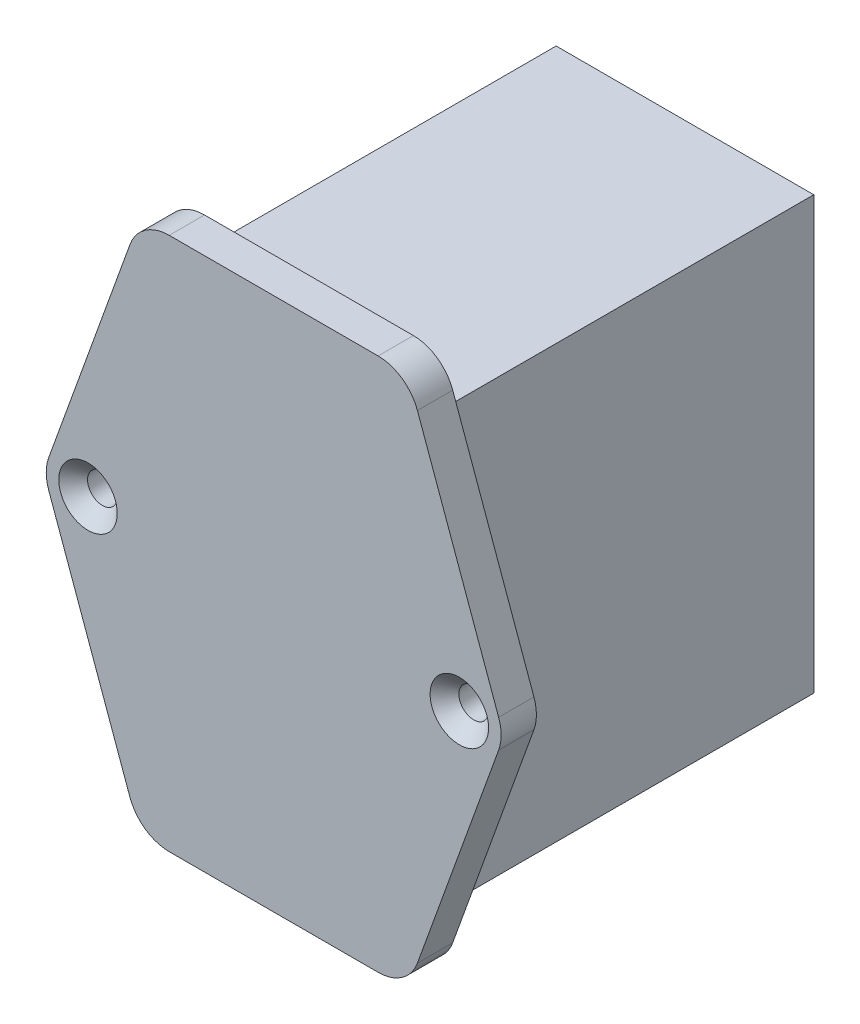
from build123d import *

# Parameters (mm, degrees)
SKETCH1_W                                       = 27.75
SKETCH1_H                                       = 46.5
BOSS_EXTRUDE1_DEPTH                             = 40.5
SKETCH2_R                                       = 1.6
BOSS_EXTRUDE2_DEPTH                             = 3.8
CSK_FOR_M3_FLAT_HEAD_MACHINE_SCREW1_D           = 3.2
CSK_FOR_M3_FLAT_HEAD_MACHINE_SCREW1_CSINK_D     = 6.3
CSK_FOR_M3_FLAT_HEAD_MACHINE_SCREW1_CSINK_ANGLE = 90


with BuildPart() as part:
    # Sketch1 → Boss-Extrude1 (new body)
    with BuildSketch(Plane.XY):
        with Locations((13.875, 23.25)):
            Rectangle(SKETCH1_W, SKETCH1_H)
    extrude(amount=BOSS_EXTRUDE1_DEPTH)

    # Sketch2 → Boss-Extrude2 (add)
    with BuildSketch(Plane.XY.offset(40.5)):
        with BuildLine():
            Line((2.625, -5.2), (25.125, -5.2))
            ThreePointArc((25.125, -5.2), (27.711215896, -4.382592475), (29.357879644, -2.227327706))
            Line((29.357879644, -2.227327706), (38.107879644, 22.022672294))
            ThreePointArc((38.107879644, 22.022672294), (38.375, 23.55), (38.107879644, 25.077327706))
            Line((38.107879644, 25.077327706), (29.357879644, 49.327327706))
            ThreePointArc((29.357879644, 49.327327706), (27.711215896, 51.482592475), (25.125, 52.3))
            Line((25.125, 52.3), (2.625, 52.3))
            ThreePointArc((2.625, 52.3), (0.038784104, 51.482592475), (-1.607879644, 49.327327706))
            Line((-1.607879644, 49.327327706), (-10.357879644, 25.077327706))
            ThreePointArc((-10.357879644, 25.077327706), (-10.625, 23.55), (-10.357879644, 22.022672294))
            Line((-10.357879644, 22.022672294), (-1.607879644, -2.227327706))
            ThreePointArc((-1.607879644, -2.227327706), (0.038784104, -4.382592475), (2.625, -5.2))
        make_face()
        with Locations((-6.125, 23.55)):
            Circle(SKETCH2_R, mode=Mode.SUBTRACT)
        with Locations((33.875, 23.55)):
            Circle(SKETCH2_R, mode=Mode.SUBTRACT)
    extrude(amount=BOSS_EXTRUDE2_DEPTH)

    # CSK for M3 Flat Head Machine Screw1 (through all)
    with Locations(Plane.XY.offset(44.3)):
        with Locations((-6.125, 23.55), (33.875, 23.55)):
            CounterSinkHole(CSK_FOR_M3_FLAT_HEAD_MACHINE_SCREW1_D / 2, CSK_FOR_M3_FLAT_HEAD_MACHINE_SCREW1_CSINK_D / 2, counter_sink_angle=CSK_FOR_M3_FLAT_HEAD_MACHINE_SCREW1_CSINK_ANGLE)


solid = part.part
